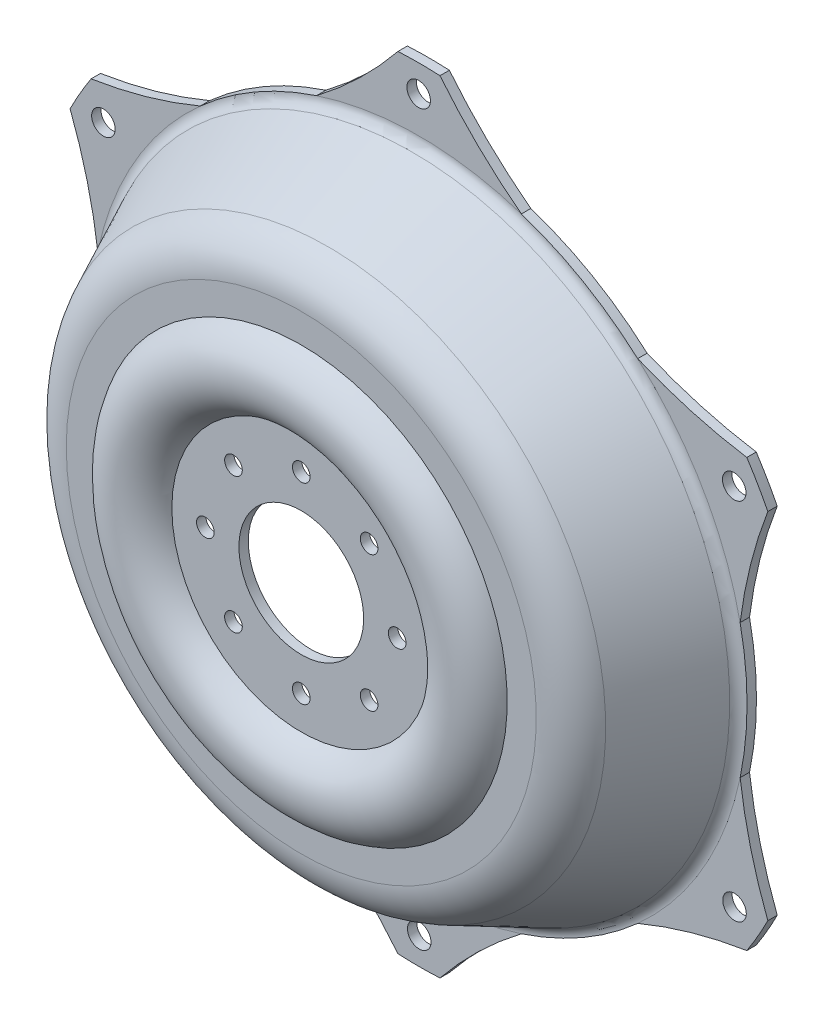
from build123d import *

# Parameters (mm, degrees)
SKETCH5_R                      = 10
CUT_EXTRUDE2_DEPTH             = 129.0000001
F_15_0_15_DIAMETER_HOLE1_D     = 15
F_15_0_15_DIAMETER_HOLE1_DEPTH = 55.6
F_15_0_15_DIAMETER_HOLE1_TIP   = 4.506454643


with BuildPart() as part:
    # Sketch3 → Revolve1 (revolve)
    with BuildSketch(Plane(origin=(0, 0, 0), x_dir=(1, 0, 0), z_dir=(0, 1, 0))):
        with BuildLine():
            Line((332.5, 100), (278.820794913, 100))
            ThreePointArc((278.820794913, 100), (269.203477405, 97.21536079), (262.561799834, 89.723022662))
            Line((262.561799834, 89.723022662), (228.621700488, 18.270181934))
            ThreePointArc((228.621700488, 18.270181934), (216.814273696, 4.950469707), (199.716820349, 0))
            Line((199.716820349, 0), (169.633927102, 0))
            ThreePointArc((169.633927102, 0), (142.5, -20), (115.366072898, 0))
            Line((115.366072898, 0), (53, 0))
            Line((53, 0), (53, -8))
            Line((53, -8), (110, -8))
            ThreePointArc((110, -8), (142.5, -28), (175, -8))
            Line((175, -8), (199.716820349, -8))
            ThreePointArc((199.716820349, -8), (221.088637032, -1.811912866), (235.847920523, 14.837727417))
            Line((235.847920523, 14.837727417), (269.788019869, 86.290568146))
            ThreePointArc((269.788019869, 86.290568146), (273.477840742, 90.452978216), (278.820794913, 92))
            Line((278.820794913, 92), (332.5, 92))
            Line((332.5, 92), (332.5, 100))
        make_face()
    revolve(axis=Axis((0, 0, 0), (0, 0, 1)))

    # Sketch5 → Cut-Extrude2 (cut, through all)
    with BuildSketch(Plane.XY.offset(-100)):
        with BuildLine():
            ThreePointArc((-272.918536119, 57.065824437), (-281.863035881, 104.522463434), (-296.461364128, 150.555337266))
            ThreePointArc((-296.461364128, 150.555337266), (-332.5, 0), (-296.461364128, -150.555337266))
            ThreePointArc((-296.461364128, -150.555337266), (-281.863035881, -104.522463434), (-272.918536119, -57.065824437))
            ThreePointArc((-272.918536119, -57.065824437), (-278.820794913, 0), (-272.918536119, 57.065824437))
        make_face()
        with BuildLine():
            ThreePointArc((-87.038814409, 264.887297661), (-50.412409341, 296.361781178), (-17.845935316, 332.020741209))
            ThreePointArc((-17.845935316, 332.020741209), (-166.25, 287.953446758), (-278.615428812, 181.465403942))
            ThreePointArc((-278.615428812, 181.465403942), (-231.45062654, 191.839317744), (-185.87972171, 207.821473224))
            ThreePointArc((-185.87972171, 207.821473224), (-139.410397456, 241.465891498), (-87.038814409, 264.887297661))
        make_face()
        with BuildLine():
            ThreePointArc((185.87972171, 207.821473224), (231.45062654, 191.839317744), (278.615428812, 181.465403942))
            ThreePointArc((278.615428812, 181.465403942), (166.25, 287.953446758), (17.845935316, 332.020741209))
            ThreePointArc((17.845935316, 332.020741209), (50.412409341, 296.361781178), (87.038814409, 264.887297661))
            ThreePointArc((87.038814409, 264.887297661), (139.410397456, 241.465891498), (185.87972171, 207.821473224))
        make_face()
        with BuildLine():
            ThreePointArc((332.5, 0), (323.364850883, 77.404284208), (296.461364128, 150.555337266))
            ThreePointArc((296.461364128, 150.555337266), (281.863035881, 104.522463434), (272.918536119, 57.065824437))
            ThreePointArc((272.918536119, 57.065824437), (277.34130495, 28.685122353), (278.820794913, 0))
            ThreePointArc((278.820794913, 0), (277.34130495, -28.685122353), (272.918536119, -57.065824437))
            ThreePointArc((272.918536119, -57.065824437), (281.863035881, -104.522463434), (296.461364128, -150.555337266))
            ThreePointArc((296.461364128, -150.555337266), (323.364850883, -77.404284208), (332.5, 0))
        make_face()
        with BuildLine():
            ThreePointArc((17.845935316, -332.020741209), (166.25, -287.953446758), (278.615428812, -181.465403942))
            ThreePointArc((278.615428812, -181.465403942), (231.45062654, -191.839317744), (185.87972171, -207.821473224))
            ThreePointArc((185.87972171, -207.821473224), (139.410397456, -241.465891498), (87.038814409, -264.887297661))
            ThreePointArc((87.038814409, -264.887297661), (50.412409341, -296.361781178), (17.845935316, -332.020741209))
        make_face()
        with BuildLine():
            ThreePointArc((-278.615428812, -181.465403942), (-166.25, -287.953446758), (-17.845935316, -332.020741209))
            ThreePointArc((-17.845935316, -332.020741209), (-50.412409341, -296.361781178), (-87.038814409, -264.887297661))
            ThreePointArc((-87.038814409, -264.887297661), (-139.410397456, -241.465891498), (-185.87972171, -207.821473224))
            ThreePointArc((-185.87972171, -207.821473224), (-231.45062654, -191.839317744), (-278.615428812, -181.465403942))
        make_face()
        with Locations((-268.15504681, 154.541834619)):
            Circle(SKETCH5_R)
        with Locations((-0.240368677, 309.5)):
            Circle(SKETCH5_R)
        with Locations((267.914678133, 154.958165381)):
            Circle(SKETCH5_R)
        with Locations((268.15504681, -154.541834619)):
            Circle(SKETCH5_R)
        with Locations((0.240368677, -309.5)):
            Circle(SKETCH5_R)
        with Locations((-267.914678133, -154.958165381)):
            Circle(SKETCH5_R)
    extrude(amount=CUT_EXTRUDE2_DEPTH, mode=Mode.SUBTRACT)

    # Ø15.0 (15) Diameter Hole1
    with Locations(Plane.XY.offset(8)):
        with Locations((0, 81.5), (57.629202667, 57.629202667), (81.5, 0), (57.629202667, -57.629202667), (0, -81.5), (-57.629202667, -57.629202667), (-81.5, 0), (-57.629202667, 57.629202667)):
            Hole(F_15_0_15_DIAMETER_HOLE1_D / 2, depth=F_15_0_15_DIAMETER_HOLE1_DEPTH)
            with Locations((0, 0, -(F_15_0_15_DIAMETER_HOLE1_DEPTH + F_15_0_15_DIAMETER_HOLE1_TIP / 2))):  # 118° drill point
                Cone(0, F_15_0_15_DIAMETER_HOLE1_D / 2, F_15_0_15_DIAMETER_HOLE1_TIP, mode=Mode.SUBTRACT)


solid = part.part
